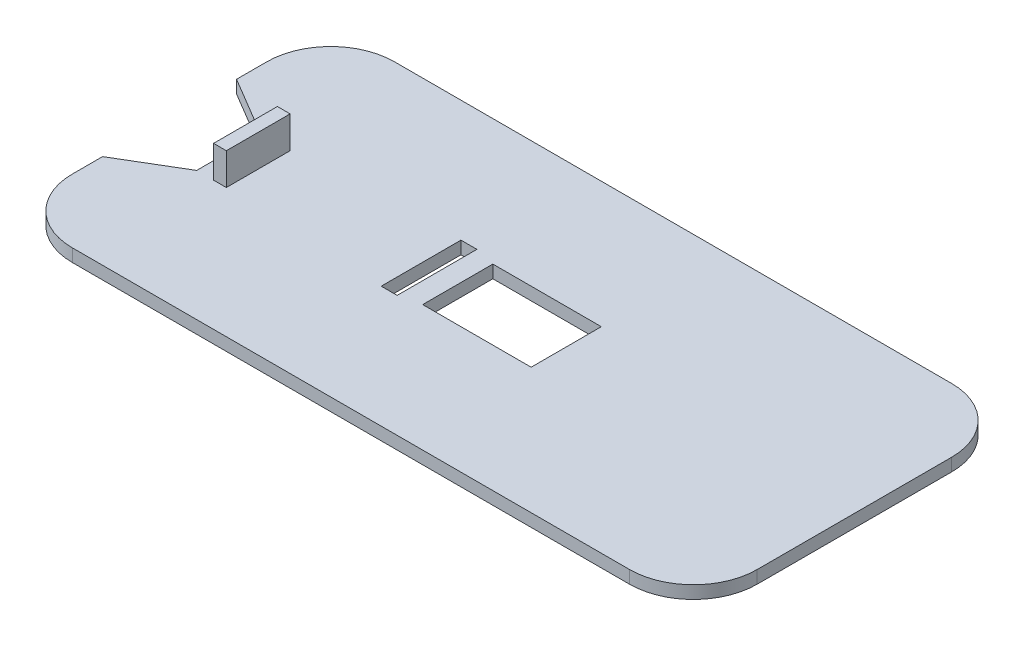
from build123d import *

# Parameters (mm, degrees)
BOSS_EXTRUDE7_DEPTH      = 4
SKETCH3_W                = 34
SKETCH3_H                = 22
CUT_EXTRUDE2_DEPTH       = 4
CUT_EXTRUDE3_DEPTH       = 4
SKETCH7_W                = 4
SKETCH7_H                = 20
BOSS_EXTRUDE9_DEPTH      = 10
BOSS_EXTRUDE9_DEPTH_BACK = 14
SKETCH9_W                = 5
SKETCH9_H                = 25
CUT_EXTRUDE4_DEPTH       = 4


with BuildPart() as part:
    # Sketch1 → Boss-Extrude7 (new body)
    with BuildSketch(Plane(origin=(0, 0, 0), x_dir=(1, 0, 0), z_dir=(0, 1, 0))):
        with BuildLine():
            Line((101.270150391, 181.252283774), (275.970150391, 181.252283774))
            ThreePointArc((275.970150391, 181.252283774), (290.112286015, 175.394419397), (295.970150391, 161.252283774))
            Line((295.970150391, 161.252283774), (295.970150391, 100.252283774))
            ThreePointArc((295.970150391, 100.252283774), (290.112286015, 86.11014815), (275.970150391, 80.252283774))
            Line((275.970150391, 80.252283774), (101.270150391, 80.252283774))
            ThreePointArc((101.270150391, 80.252283774), (87.128014768, 86.11014815), (81.270150391, 100.252283774))
            Line((81.270150391, 100.252283774), (81.270150391, 161.252283774))
            ThreePointArc((81.270150391, 161.252283774), (87.128014768, 175.394419397), (101.270150391, 181.252283774))
        make_face()
    extrude(amount=BOSS_EXTRUDE7_DEPTH)

    # Sketch3 → Cut-Extrude2 (cut)
    with BuildSketch(Plane(origin=(0, 4, 0), x_dir=(1, 0, 0), z_dir=(0, 1, 0))):
        with Locations((188.620150391, 130.752283774)):
            Rectangle(SKETCH3_W, SKETCH3_H)
    extrude(amount=-CUT_EXTRUDE2_DEPTH, mode=Mode.SUBTRACT)

    # Sketch6 → Cut-Extrude3 (cut)
    with BuildSketch(Plane(origin=(0, 4, 0), x_dir=(1, 0, 0), z_dir=(0, 1, 0))):
        Polygon((81.270150391, 151.752283774), (81.270150391, 109.752283774), (99.770150391, 120.752283774), (99.770150391, 140.752283774), align=None)
    extrude(amount=-CUT_EXTRUDE3_DEPTH, mode=Mode.SUBTRACT)

    # Sketch7 → Boss-Extrude9 (add, two sides)
    with BuildSketch(Plane(origin=(0, 4, 0), x_dir=(1, 0, 0), z_dir=(0, 1, 0))) as boss_extrude9_sk:
        with Locations((107.070150391, 130.752283774)):
            Rectangle(SKETCH7_W, SKETCH7_H)
    extrude(amount=BOSS_EXTRUDE9_DEPTH)
    extrude(boss_extrude9_sk.sketch, amount=-BOSS_EXTRUDE9_DEPTH_BACK)

    # Sketch9 → Cut-Extrude4 (cut)
    with BuildSketch(Plane(origin=(0, 0, 0), x_dir=(-1, 0, 0), z_dir=(0, -1, 0))):
        with Locations((-162.620150391, 130.752283774)):
            Rectangle(SKETCH9_W, SKETCH9_H)
    extrude(amount=-CUT_EXTRUDE4_DEPTH, mode=Mode.SUBTRACT)


solid = part.part
